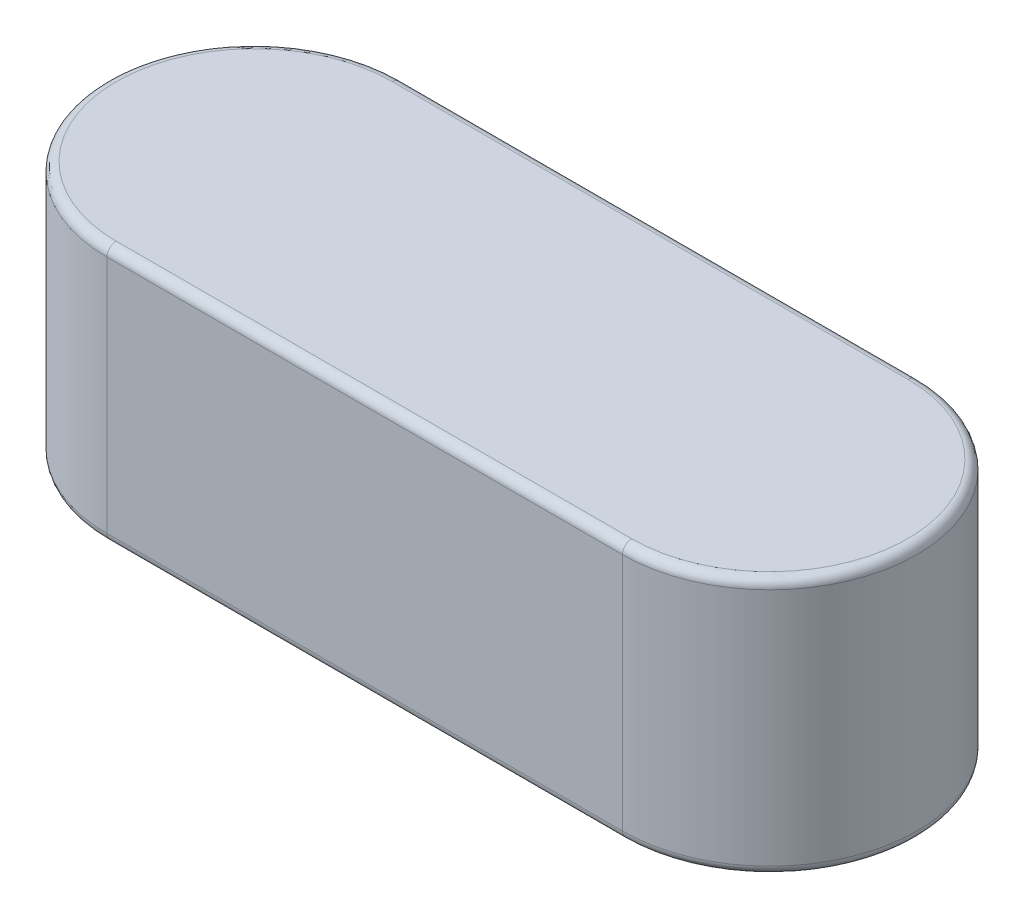
from build123d import *

# Parameters (mm, degrees)
EXTRUDE1_DEPTH = 7
FILLET1_R      = 0.25


with BuildPart() as part:
    # Sketch1 → Extrude1 (new body)
    with BuildSketch(Plane(origin=(0, 0, 0), x_dir=(1, 0, 0), z_dir=(0, 1, 0))):
        with BuildLine():
            Line((-14, 4), (0, 4))
            ThreePointArc((0, 4), (4, 0), (0, -4))
            Line((0, -4), (-14, -4))
            ThreePointArc((-14, -4), (-18, 0), (-14, 4))
        make_face()
    extrude(amount=EXTRUDE1_DEPTH)

    # Fillet1
    fillet1_edges = [part.edges().sort_by_distance(p)[0] for p in [
        (4, 7, 0),
        (-7, 7, -4),
        (-18, 7, 0),
        (-7, 0, -4),
        (4, 0, 0),
        (-7, 0, 4),
        (-18, 0, 0),
        (-7, 7, 4),
    ]]
    fillet(fillet1_edges, radius=FILLET1_R)


solid = part.part
